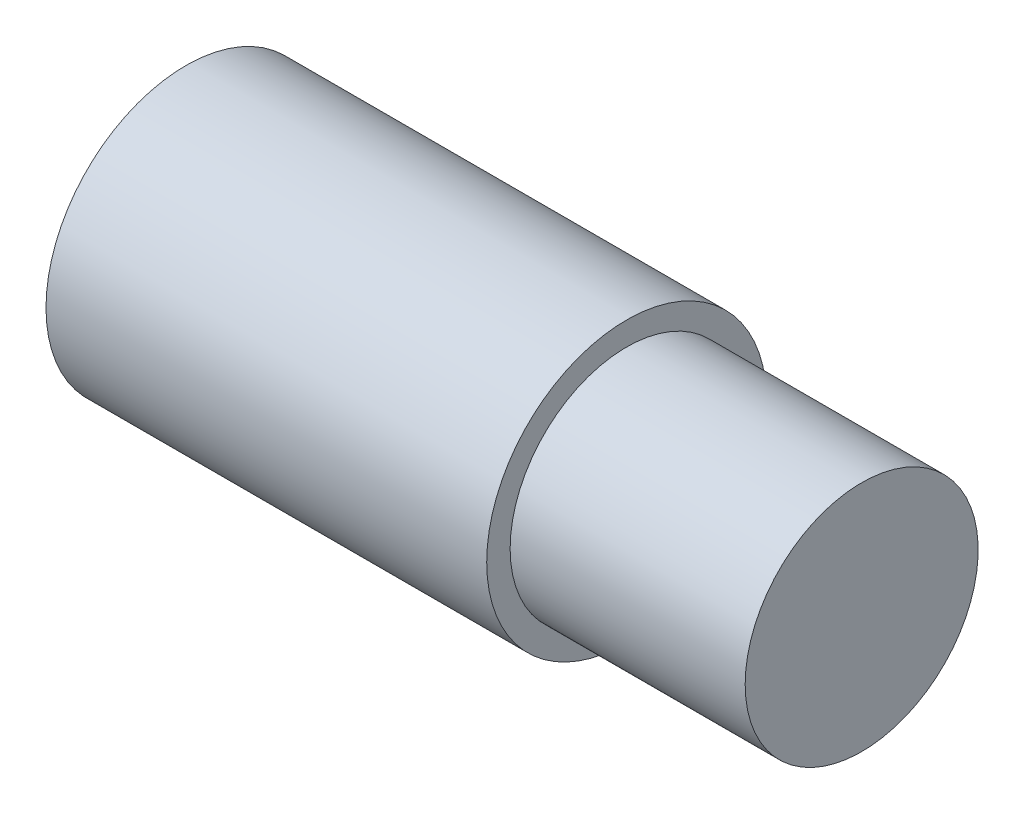
from build123d import *


with BuildPart() as part:
    # Sketch1 → Revolve1 (revolve)
    with BuildSketch(Plane.XY, mode=Mode.PRIVATE) as revolve1_sk:
        Polygon((0, 0), (0, 4.7625), (15, 4.7625), (15, 3.965), (23, 3.965), (23, 0), align=None)
    revolve(revolve1_sk.sketch.rotate(Axis((-58.055198008, 0, 0), (1, 0, 0)), 90), axis=Axis((-58.055198008, 0, 0), (1, 0, 0)))  # turned: the seam where the file's is


solid = part.part
